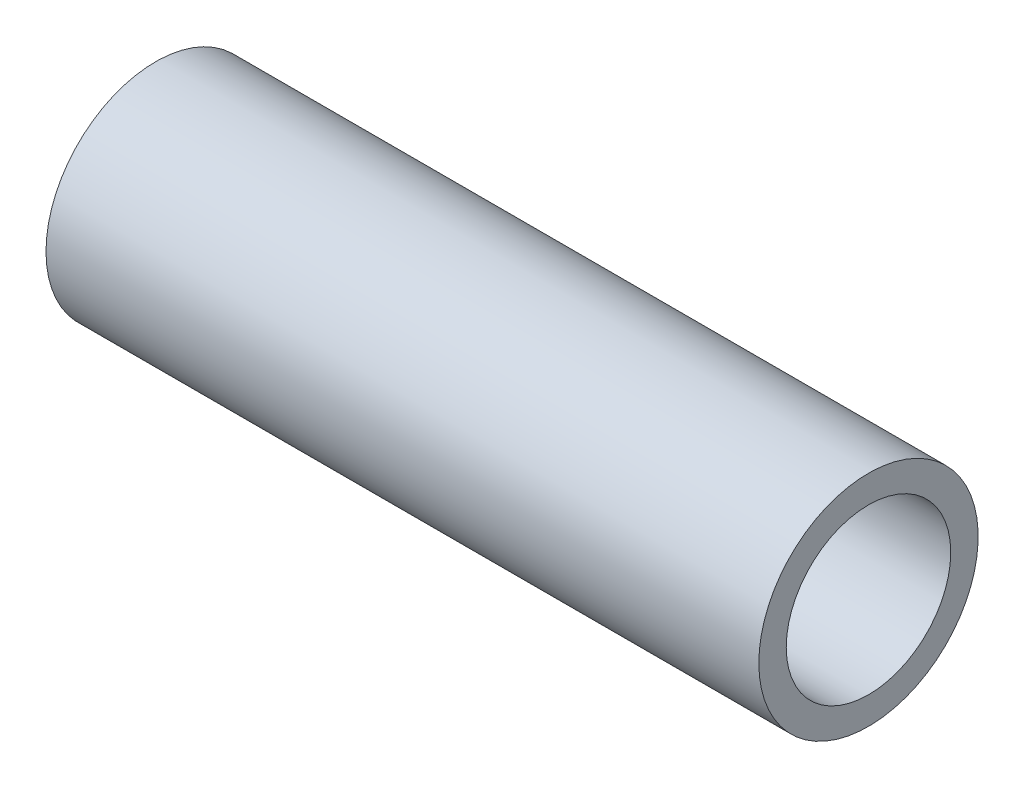
from build123d import *


with BuildPart() as part:
    # Sketch1 → Revolve1 (revolve)
    with BuildSketch(Plane(origin=(0, 0, 0), x_dir=(1, 0, 0), z_dir=(0, 1, 0)), mode=Mode.PRIVATE) as revolve1_sk:
        Polygon((-6.5, 0), (-6, 0), (-5.598076211, 1.5), (6.5, 1.5), (6.5, 2), (-6.5, 2), align=None)
    revolve(revolve1_sk.sketch.rotate(Axis((-6, 0, 0), (1, 0, 0)), 180), axis=Axis((-6, 0, 0), (1, 0, 0)))  # turned: the seam where the file's is


solid = part.part
